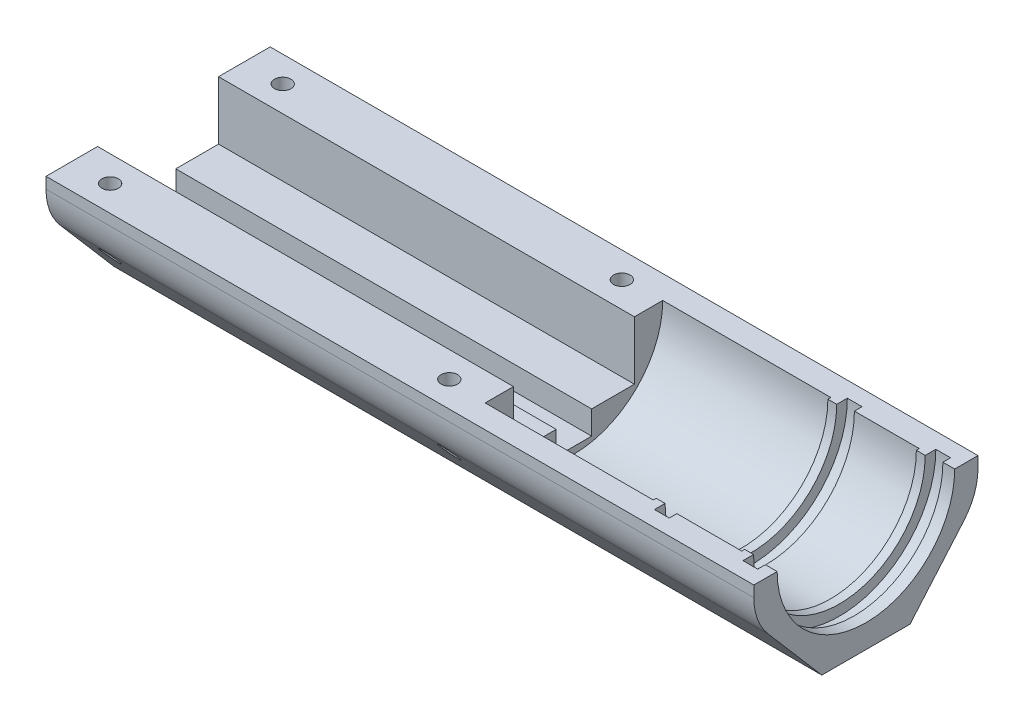
from build123d import *

# Parameters (mm, degrees)
R_VOLUTION1_ANGLE       = 180
ENL_V_START             = -19
ESQUISSE2_W             = 120
ESQUISSE2_H             = 50.1
ENL_V_MAT_EXTRU_1_DEPTH = 10
ESQUISSE3_W             = 146.438377439
ESQUISSE3_H             = 50.311635948
ENL_V_MAT_EXTRU_2_DEPTH = 10
ESQUISSE4_W             = 156.060048108
ESQUISSE4_H             = 43.154210134
ENL_V_MAT_EXTRU_3_DEPTH = 7
CONG_1_R                = 10
ENL_V_MAT_EXTRU_4_DEPTH = 121
ESQUISSE6_R             = 1.4
ENL_V_MAT_EXTRU_5_DEPTH = 20


with BuildPart() as part:
    # Esquisse1 → Révolution1 (revolve, symmetric)
    with BuildSketch(Plane.XY) as r_volution1_sk:
        Polygon((70.5, -15.05), (99, -15.05), (99, -14.55), (100.5, -14.55), (100.5, -15.05), (100.5, -16.35), (103, -16.35), (103, -15.05), (114, -15.05), (114, -14.55), (115.5, -14.55), (115.5, -15.05), (115.5, -16.35), (118, -16.35), (118, -15.05), (120, -15.05), (120, -25.05), (0, -25.05), (0, -15.05), (0, -9.55), (70.5, -9.55), align=None)
    revolve(axis=Axis((0, 0, 0), (1, 0, 0)), revolution_arc=R_VOLUTION1_ANGLE / 2)
    revolve(r_volution1_sk.sketch, axis=Axis((0, 0, 0), (-1, 0, 0)), revolution_arc=R_VOLUTION1_ANGLE / 2)

    # Esquisse2 → Enlèv. mat.-Extru.1 (cut)
    with BuildSketch(Plane(origin=(0, 0, 0), x_dir=(1, 0, 0), z_dir=(0, 1, 0)).offset(ENL_V_START)):
        with Locations((60, 0)):
            Rectangle(ESQUISSE2_W, ESQUISSE2_H)
    extrude(amount=-ENL_V_MAT_EXTRU_1_DEPTH, mode=Mode.SUBTRACT)

    # Esquisse3 → Enlèv. mat.-Extru.2 (cut)
    with BuildSketch(Plane.XY.offset(ENL_V_START)):
        with Locations((56.62202011, -13.21090671)):
            Rectangle(ESQUISSE3_W, ESQUISSE3_H)
    enl_v_mat_extru_2 = extrude(amount=-ENL_V_MAT_EXTRU_2_DEPTH, mode=Mode.SUBTRACT)

    # Esquisse4 → Enlèv. mat.-Extru.3 (cut)
    with BuildSketch(Plane(origin=(0, -16.324904288, -19), x_dir=(-1, 0, 0), z_dir=(0, -0.651692786, -0.758483034))):
        with Locations((-53.986796091, -2.160595236)):
            Rectangle(ESQUISSE4_W, ESQUISSE4_H)
    enl_v_mat_extru_3 = extrude(amount=-ENL_V_MAT_EXTRU_3_DEPTH, mode=Mode.SUBTRACT)

    # Symétrie1: Enlèv. mat.-Extru.2, Enlèv. mat.-Extru.3 across plane
    add(enl_v_mat_extru_2.mirror(Plane.XY), mode=Mode.SUBTRACT)
    add(enl_v_mat_extru_3.mirror(Plane.XY), mode=Mode.SUBTRACT)

    # Congé1
    cong_1_edges = [part.edges().sort_by_distance(p)[0] for p in [
        (60, -5.583646825, 19),
        (60, -5.583646825, -19),
    ]]
    fillet(cong_1_edges, radius=CONG_1_R)

    # Esquisse5 → Enlèv. mat.-Extru.4 (cut, through all)
    with BuildSketch(Plane.ZY):
        Polygon((10.25, 0), (-10.25, 0), (-10.25, -9.9), (-3, -9.9), (-3, -13.9), (3, -13.9), (3, -9.9), (10.25, -9.9), align=None)
    extrude(amount=-ENL_V_MAT_EXTRU_4_DEPTH, mode=Mode.SUBTRACT)

    # Esquisse6 → Enlèv. mat.-Extru.5 (cut, through all)
    with BuildSketch(Plane(origin=(0, 0, 0), x_dir=(1, 0, 0), z_dir=(0, 1, 0))):
        with Locations((6.5, 14.625)):
            Circle(ESQUISSE6_R)
        with Locations((64, 14.625)):
            Circle(ESQUISSE6_R)
    enl_v_mat_extru_5 = extrude(amount=-ENL_V_MAT_EXTRU_5_DEPTH, mode=Mode.SUBTRACT)

    # Symétrie2: Enlèv. mat.-Extru.5 across plane
    add(enl_v_mat_extru_5.mirror(Plane.XY), mode=Mode.SUBTRACT)


solid = part.part
